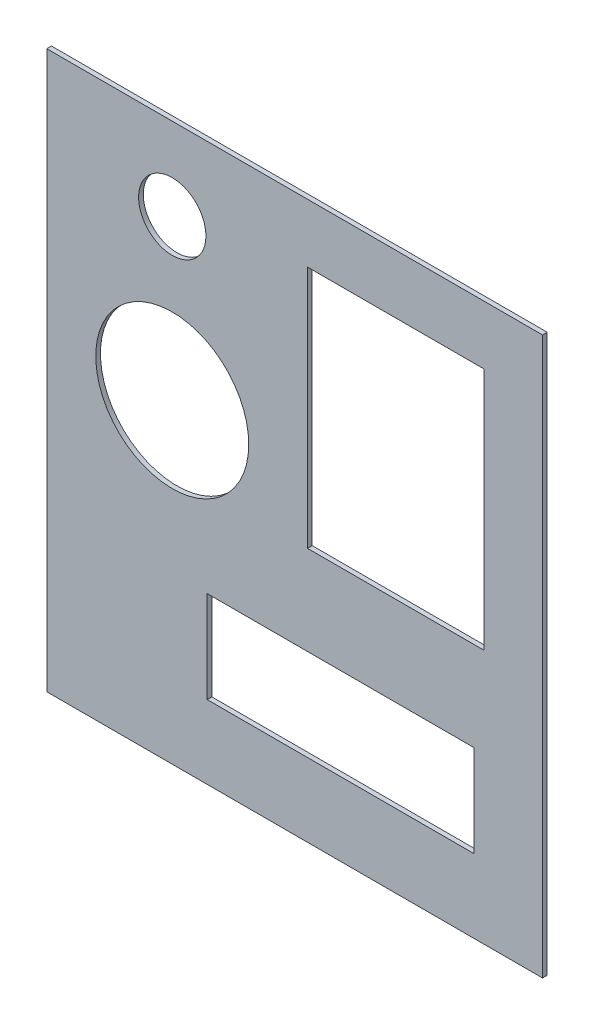
from build123d import *

# Parameters (mm, degrees)
SKETCH1_W           = 128.5875
SKETCH1_H           = 144.4625
BOSS_EXTRUDE1_DEPTH = 1.21412
SKETCH3_R           = 8.73125
SKETCH3_R_2         = 19.84375
SKETCH3_W           = 79.375
SKETCH3_H           = 36.5125
SKETCH3_W_2         = 50.8
SKETCH3_H_2         = 68.2625
CUT_EXTRUDE1_DEPTH  = 2.21412
SKETCH4_W           = 50.8
SKETCH4_H           = 68.2625
SKETCH4_W_2         = 45.72
SKETCH4_H_2         = 63.1825
BOSS_EXTRUDE2_DEPTH = 1.21412
SKETCH5_W           = 79.375
SKETCH5_H           = 36.5125
SKETCH5_W_2         = 69.215
SKETCH5_H_2         = 23.8125
BOSS_EXTRUDE3_DEPTH = 1.21412


with BuildPart() as part:
    # Sketch1 → Boss-Extrude1 (new body)
    with BuildSketch(Plane.XY):
        Rectangle(SKETCH1_W, SKETCH1_H)
    extrude(amount=BOSS_EXTRUDE1_DEPTH)

    # Sketch3 → Cut-Extrude1 (cut, through all)
    with BuildSketch(Plane.XY.offset(1.21412)):
        with Locations((-31.75, 50.8)):
            Circle(SKETCH3_R)
        with Locations((-31.75, 9.525)):
            Circle(SKETCH3_R_2)
        with Locations((11.90625, -41.275)):
            Rectangle(SKETCH3_W, SKETCH3_H)
        with Locations((26.19375, 25.4)):
            Rectangle(SKETCH3_W_2, SKETCH3_H_2)
    extrude(amount=-CUT_EXTRUDE1_DEPTH, mode=Mode.SUBTRACT)

    # Sketch4 → Boss-Extrude2 (add)
    with BuildSketch(Plane.XY.offset(1.21412)):
        with Locations((26.19375, 25.4)):
            Rectangle(SKETCH4_W, SKETCH4_H)
        with Locations((26.19375, 25.4)):
            Rectangle(SKETCH4_W_2, SKETCH4_H_2, mode=Mode.SUBTRACT)
    extrude(amount=-BOSS_EXTRUDE2_DEPTH)

    # Sketch5 → Boss-Extrude3 (add)
    with BuildSketch(Plane.XY.offset(1.21412)):
        with Locations((11.90625, -41.275)):
            Rectangle(SKETCH5_W, SKETCH5_H)
        with Locations((11.90625, -41.275)):
            Rectangle(SKETCH5_W_2, SKETCH5_H_2, mode=Mode.SUBTRACT)
    extrude(amount=-BOSS_EXTRUDE3_DEPTH)


solid = part.part
